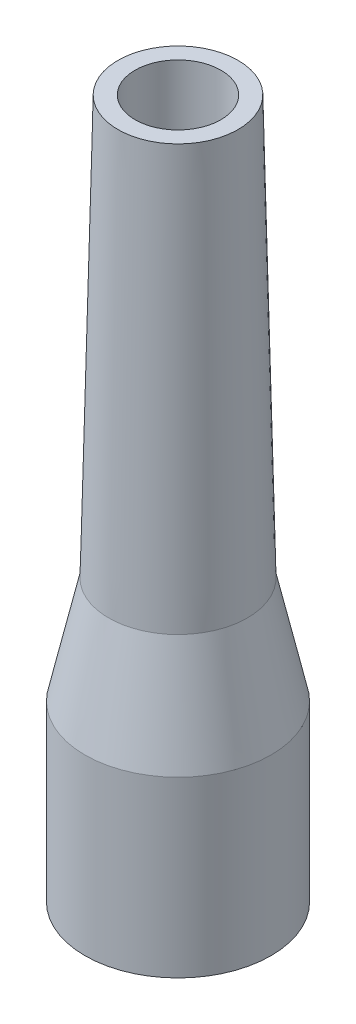
from build123d import *


with BuildPart() as part:
    # Sketch1 → Revolve1 (revolve)
    with BuildSketch(Plane(origin=(0, 0, 0), x_dir=(0, 0, -1), z_dir=(1, 0, 0))):
        Polygon((-4.999970175, 38.890840172), (-5.949970175, 0.002442159), (-8.449970175, 0.002442159), (-8.449970175, 15.793389561), (-6.30002502, 25.491165452), (-5.45002502, 63.481657683), (-3.9, 63.481657683), (-3.9, 43.852484994), align=None)
    revolve(axis=Axis((0, 0, 0), (0, 1, 0)))


solid = part.part
